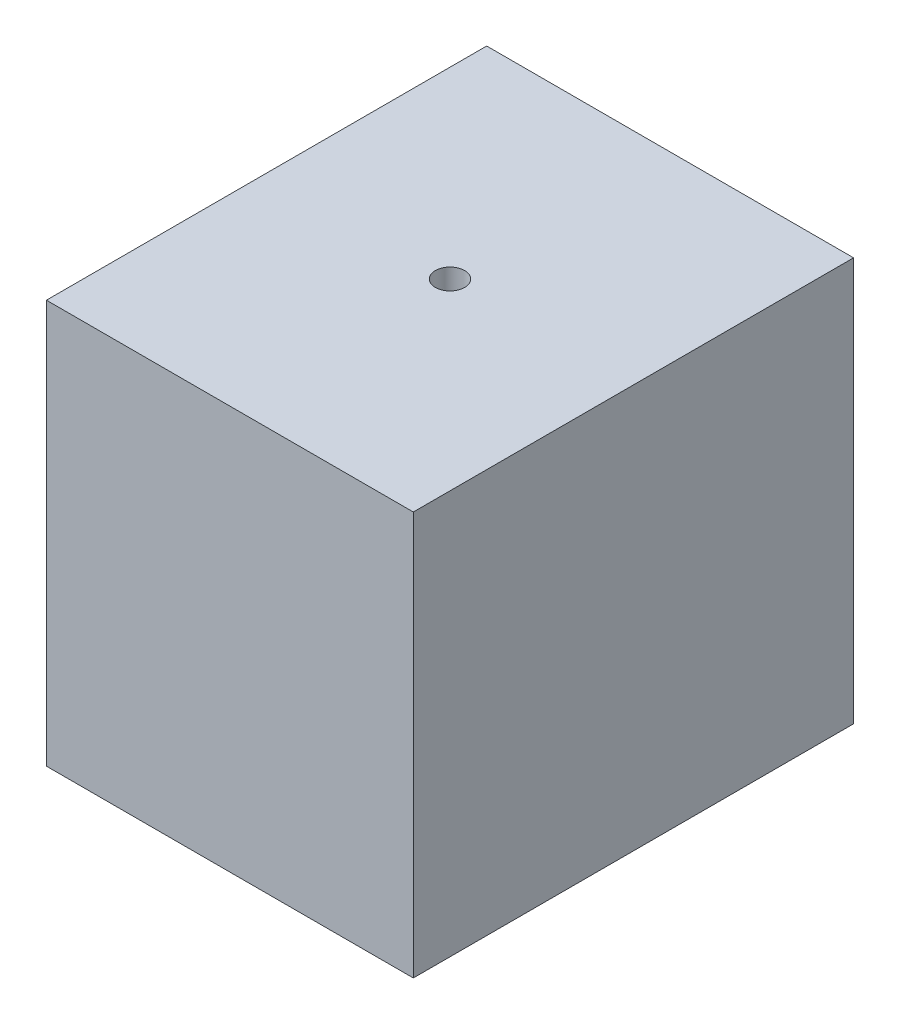
from build123d import *

# Parameters (mm, degrees)
SKETCH_1_W          = 50
SKETCH_1_H          = 55
EXTRUDE_1_DEPTH     = 30
EXTRUDE_2_DEPTH     = 10
SKETCH_3_R          = 2
CUT_EXTRUDE_1_DEPTH = 10


with BuildPart() as part:
    # 草图1 → 凸台-拉伸1 (new body, symmetric)
    with BuildSketch(Plane.XY):
        Rectangle(SKETCH_1_W, SKETCH_1_H)
    extrude(amount=EXTRUDE_1_DEPTH, both=True)

    # 草图2 → 凸台-拉伸2 (add)
    with BuildSketch(Plane(origin=(0, 0, -30), x_dir=(-1, 0, 0), z_dir=(0, 0, -1))):
        with BuildLine():
            Line((11.180339887, 10), (-11.180339887, 10))
            ThreePointArc((-11.180339887, 10), (0, -15), (11.180339887, 10))
        make_face()
    extrude(amount=EXTRUDE_2_DEPTH)

    # 草图3 → 切除-拉伸1 (cut)
    with BuildSketch(Plane(origin=(0, 27.5, 0), x_dir=(1, 0, 0), z_dir=(0, 1, 0))):
        Circle(SKETCH_3_R)
    extrude(amount=-CUT_EXTRUDE_1_DEPTH, mode=Mode.SUBTRACT)


solid = part.part
